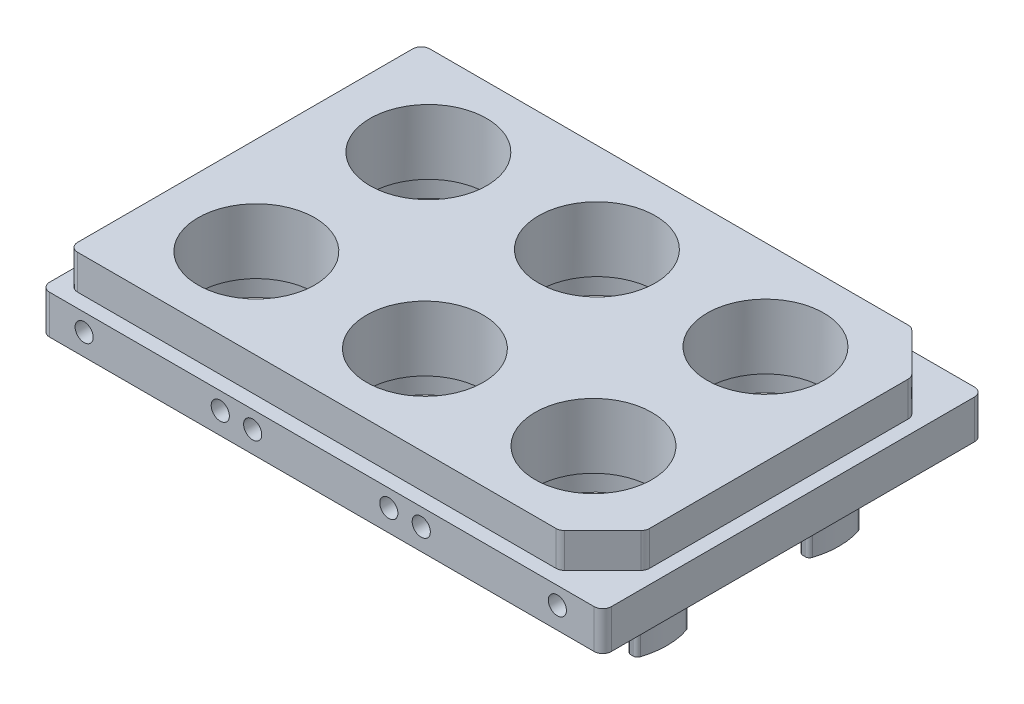
from build123d import *

# Parameters (mm, degrees)
SKETCH1_W           = 123.5
SKETCH1_H           = 81.5
BOSS_EXTRUDE1_DEPTH = 8
CHAMFER1_SIZE       = 10
SKETCH2_W           = 130
SKETCH2_H           = 88
BOSS_EXTRUDE2_DEPTH = 9
FILLET1_R           = 2
SKETCH3_W           = 124
SKETCH3_H           = 82
CUT_EXTRUDE1_DEPTH  = 2
FILLET2_R           = 2
SKETCH4_R           = 13.5
CUT_EXTRUDE2_DEPTH  = 18
SKETCH5_R           = 17
SKETCH5_R_2         = 14.5
BOSS_EXTRUDE3_DEPTH = 16.5
SKETCH6_W           = 170
SKETCH6_H           = 36.5
SKETCH6_W_2         = 114
SKETCH6_H_2         = 12
CUT_EXTRUDE3_DEPTH  = 12
FILLET3_R           = 1
SKETCH7_R           = 0.85
CUT_EXTRUDE4_DEPTH  = 20.75
SKETCH8_R           = 2.1
CUT_EXTRUDE5_DEPTH  = 26
SKETCH9_R           = 2.1
CUT_EXTRUDE6_DEPTH  = 26


with BuildPart() as part:
    # Sketch1 → Boss-Extrude1 (new body)
    with BuildSketch(Plane(origin=(0, 0, 0), x_dir=(1, 0, 0), z_dir=(0, 1, 0))):
        with Locations((61.75, -40.75)):
            Rectangle(SKETCH1_W, SKETCH1_H)
    extrude(amount=BOSS_EXTRUDE1_DEPTH)

    # Chamfer1
    chamfer1_edges = [part.edges().sort_by_distance(p)[0] for p in [
        (123.5, 4, 0),
        (123.5, 4, 81.5),
    ]]
    chamfer(chamfer1_edges, length=CHAMFER1_SIZE)

    # Sketch2 → Boss-Extrude2 (add)
    with BuildSketch(Plane.XZ):
        with Locations((61.75, 40.75)):
            Rectangle(SKETCH2_W, SKETCH2_H)
    extrude(amount=BOSS_EXTRUDE2_DEPTH)

    # Fillet1
    fillet1_edges = [part.edges().sort_by_distance(p)[0] for p in [
        (113.5, 4, 0),
        (123.5, 4, 71.5),
        (123.5, 4, 10),
        (113.5, 4, 81.5),
        (-3.25, -4.5, 84.75),
        (-3.25, -4.5, -3.25),
        (126.75, -4.5, -3.25),
        (126.75, -4.5, 84.75),
        (0, 4, 0),
        (0, 4, 81.5),
    ]]
    fillet(fillet1_edges, radius=FILLET1_R)

    # Sketch3 → Cut-Extrude1 (cut)
    with BuildSketch(Plane.XZ.offset(9)):
        with Locations((61.75, 40.75)):
            Rectangle(SKETCH3_W, SKETCH3_H)
    extrude(amount=-CUT_EXTRUDE1_DEPTH, mode=Mode.SUBTRACT)

    # Fillet2
    fillet2_edges = [part.edges().sort_by_distance(p)[0] for p in [
        (-0.25, -8, -0.25),
        (-0.25, -8, 81.75),
        (123.75, -8, 81.75),
        (123.75, -8, -0.25),
    ]]
    fillet(fillet2_edges, radius=FILLET2_R)

    # Sketch4 → Cut-Extrude2 (cut, through all)
    with BuildSketch(Plane(origin=(0, 8, 0), x_dir=(1, 0, 0), z_dir=(0, 1, 0))):
        with Locations((22.5, -20.85)):
            Circle(SKETCH4_R)
        with Locations((61.5, -20.85)):
            Circle(SKETCH4_R)
        with Locations((100.5, -20.85)):
            Circle(SKETCH4_R)
        with Locations((100.5, -60.65)):
            Circle(SKETCH4_R)
        with Locations((61.5, -60.65)):
            Circle(SKETCH4_R)
        with Locations((22.5, -60.65)):
            Circle(SKETCH4_R)
    extrude(amount=-CUT_EXTRUDE2_DEPTH, mode=Mode.SUBTRACT)

    # Sketch5 → Boss-Extrude3 (add)
    with BuildSketch(Plane.XZ.offset(7)):
        with Locations((22.5, 60.65)):
            Circle(SKETCH5_R)
        with Locations((22.5, 60.65)):
            Circle(SKETCH5_R_2, mode=Mode.SUBTRACT)
        with Locations((61.5, 60.65)):
            Circle(SKETCH5_R)
        with Locations((61.5, 60.65)):
            Circle(SKETCH5_R_2, mode=Mode.SUBTRACT)
        with Locations((100.5, 60.65)):
            Circle(SKETCH5_R)
        with Locations((100.5, 60.65)):
            Circle(SKETCH5_R_2, mode=Mode.SUBTRACT)
        with Locations((100.5, 20.85)):
            Circle(SKETCH5_R)
        with Locations((100.5, 20.85)):
            Circle(SKETCH5_R_2, mode=Mode.SUBTRACT)
        with Locations((61.5, 20.85)):
            Circle(SKETCH5_R)
        with Locations((61.5, 20.85)):
            Circle(SKETCH5_R_2, mode=Mode.SUBTRACT)
        with Locations((22.5, 20.85)):
            Circle(SKETCH5_R)
        with Locations((22.5, 20.85)):
            Circle(SKETCH5_R_2, mode=Mode.SUBTRACT)
    extrude(amount=BOSS_EXTRUDE3_DEPTH)

    # Sketch6 → Cut-Extrude3 (cut)
    with BuildSketch(Plane.XZ.offset(23.5)):
        with Locations((61.5, 20.85)):
            Rectangle(SKETCH6_W, SKETCH6_H)
        with Locations((61.5, 20.85)):
            Rectangle(SKETCH6_W_2, SKETCH6_H_2, mode=Mode.SUBTRACT)
        with Locations((61.5, 60.65)):
            Rectangle(SKETCH6_W, SKETCH6_H)
        with Locations((61.5, 60.65)):
            Rectangle(SKETCH6_W_2, SKETCH6_H_2, mode=Mode.SUBTRACT)
    extrude(amount=-CUT_EXTRUDE3_DEPTH, mode=Mode.SUBTRACT)

    # Fillet3
    fillet3_edges = [part.edges().sort_by_distance(p)[0] for p in [
        (87.299621218, -17.5, 66.65),
        (113.700378782, -17.5, 66.65),
        (113.700378782, -17.5, 54.65),
        (87.299621218, -17.5, 54.65),
        (9.299621218, -17.5, 54.65),
        (35.700378782, -17.5, 54.65),
        (6.594026279, -17.5, 54.65),
        (48.299621218, -17.5, 54.65),
        (74.700378782, -17.5, 54.65),
        (38.405973721, -17.5, 54.65),
        (45.594026279, -17.5, 54.65),
        (77.405973721, -17.5, 54.65),
        (84.594026279, -17.5, 54.65),
        (35.700378782, -17.5, 66.65),
        (9.299621218, -17.5, 66.65),
        (38.405973721, -17.5, 66.65),
        (45.594026279, -17.5, 66.65),
        (74.700378782, -17.5, 66.65),
        (48.299621218, -17.5, 66.65),
        (77.405973721, -17.5, 66.65),
        (84.594026279, -17.5, 66.65),
        (116.405973721, -17.5, 66.65),
        (116.405973721, -17.5, 54.65),
        (6.594026279, -17.5, 66.65),
        (35.700378782, -17.5, 14.85),
        (9.299621218, -17.5, 14.85),
        (9.299621218, -17.5, 26.85),
        (35.700378782, -17.5, 26.85),
        (113.700378782, -17.5, 26.85),
        (87.299621218, -17.5, 26.85),
        (116.405973721, -17.5, 26.85),
        (74.700378782, -17.5, 26.85),
        (48.299621218, -17.5, 26.85),
        (84.594026279, -17.5, 26.85),
        (77.405973721, -17.5, 26.85),
        (45.594026279, -17.5, 26.85),
        (38.405973721, -17.5, 26.85),
        (87.299621218, -17.5, 14.85),
        (113.700378782, -17.5, 14.85),
        (84.594026279, -17.5, 14.85),
        (77.405973721, -17.5, 14.85),
        (48.299621218, -17.5, 14.85),
        (74.700378782, -17.5, 14.85),
        (45.594026279, -17.5, 14.85),
        (38.405973721, -17.5, 14.85),
        (6.594026279, -17.5, 14.85),
        (6.594026279, -17.5, 26.85),
        (116.405973721, -17.5, 14.85),
    ]]
    fillet(fillet3_edges, radius=FILLET3_R)

    # Sketch7 → Cut-Extrude4 (cut)
    with BuildSketch(Plane.XZ.offset(23.5)):
        with Locations((6.75, 20.85)):
            Circle(SKETCH7_R)
        with Locations((38.25, 20.85)):
            Circle(SKETCH7_R)
        with Locations((45.75, 20.85)):
            Circle(SKETCH7_R)
        with Locations((77.25, 20.85)):
            Circle(SKETCH7_R)
        with Locations((84.75, 20.85)):
            Circle(SKETCH7_R)
        with Locations((116.25, 20.85)):
            Circle(SKETCH7_R)
        with Locations((116.25, 60.65)):
            Circle(SKETCH7_R)
        with Locations((84.75, 60.65)):
            Circle(SKETCH7_R)
        with Locations((77.25, 60.65)):
            Circle(SKETCH7_R)
        with Locations((45.75, 60.65)):
            Circle(SKETCH7_R)
        with Locations((38.25, 60.65)):
            Circle(SKETCH7_R)
        with Locations((6.75, 60.65)):
            Circle(SKETCH7_R)
    extrude(amount=-CUT_EXTRUDE4_DEPTH, mode=Mode.SUBTRACT)

    # Sketch8 → Cut-Extrude5 (cut)
    with BuildSketch(Plane.XY.offset(84.75)):
        with Locations((6.75, -4)):
            Circle(SKETCH8_R)
        with Locations((38.25, -4)):
            Circle(SKETCH8_R)
        with Locations((116.25, -4)):
            Circle(SKETCH8_R)
        with Locations((77.25, -4)):
            Circle(SKETCH8_R)
        with Locations((45.75, -4)):
            Circle(SKETCH8_R)
        with Locations((84.75, -4)):
            Circle(SKETCH8_R)
    extrude(amount=-CUT_EXTRUDE5_DEPTH, mode=Mode.SUBTRACT)

    # Sketch9 → Cut-Extrude6 (cut)
    with BuildSketch(Plane(origin=(0, 0, -3.25), x_dir=(-1, 0, 0), z_dir=(0, 0, -1))):
        with Locations((-6.75, -4)):
            Circle(SKETCH9_R)
        with Locations((-38.25, -4)):
            Circle(SKETCH9_R)
        with Locations((-45.75, -4)):
            Circle(SKETCH9_R)
        with Locations((-77.25, -4)):
            Circle(SKETCH9_R)
        with Locations((-84.75, -4)):
            Circle(SKETCH9_R)
        with Locations((-116.25, -4)):
            Circle(SKETCH9_R)
    extrude(amount=-CUT_EXTRUDE6_DEPTH, mode=Mode.SUBTRACT)


solid = part.part
